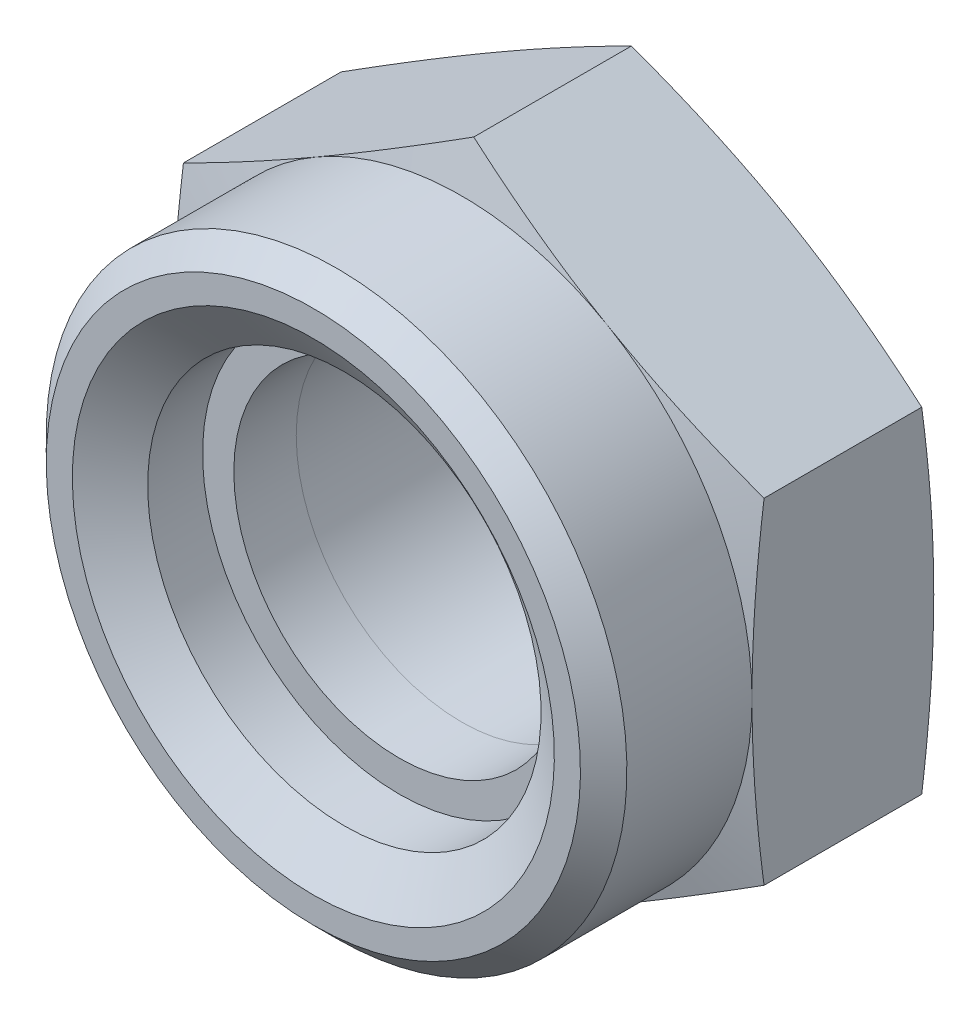
from build123d import *
from OCP.BRepFilletAPI import BRepFilletAPI_MakeChamfer

# Parameters (mm, degrees)
SKETCH_1_R          = 5.0528125
EXTRUDE_204_DEPTH   = 5.7
SKETCH_8_OUTSIDE_W  = 142.394
SKETCH_8_OUTSIDE_H  = 145.136
SKETCH_8_OUTSIDE_R  = 8.3
CUT_EXTRUDE_4_DEPTH = 15.692260718
CUT_EXTRUDE_4_DRAFT = -75
SKETCH_11_R         = 17.73
SKETCH_11_R_2       = 8.865
CUT_EXTRUDE_5_DEPTH = 1
CUT_EXTRUDE_5_DRAFT = -75
SKETCH_10_W         = 1.90609375
SKETCH_10_H         = 1.90609375
CHAMFER_1_SIZE      = 0.7092
CHAMFER_2_SIZE      = 0.9471875
CHAMFER_2_SIZE2     = 1.35272394


with BuildPart() as part:
    # 草图1 → Extrude 204 (new body)
    with BuildSketch(Plane.XY):
        Polygon((0, 10.236420273), (-8.865, 5.118210136), (-8.865, -5.118210136), (0, -10.236420273), (8.865, -5.118210136), (8.865, 5.118210136), align=None)
        Circle(SKETCH_1_R, mode=Mode.SUBTRACT)
    extrude(amount=EXTRUDE_204_DEPTH)


with BuildPart() as cut_extrude_4_tool:
    # 草图8 outside → 切除-拉伸4 (with draft: the straight prism first)
    with BuildSketch(Plane(origin=(0, 0, 0), x_dir=(-1, 0, 0), z_dir=(0, 0, -1))):
        Rectangle(SKETCH_8_OUTSIDE_W, SKETCH_8_OUTSIDE_H)
        Circle(SKETCH_8_OUTSIDE_R, mode=Mode.SUBTRACT)
    extrude(amount=-CUT_EXTRUDE_4_DEPTH)
    # 切除-拉伸4: the draft: its side faces are tilted about the plane it starts from
    cut_extrude_4_sides = [cut_extrude_4_tool.faces().sort_by_distance(p)[0] for p in [
        (0, -72.568, 7.846130359),
        (-71.197, 0, 7.846130359),
        (0, 72.568, 7.846130359),
        (71.197, 0, 7.846130359),
        (8.3, 0, 7.846130359),
    ]]
    draft(cut_extrude_4_sides, Plane(origin=(0, 0, 0), x_dir=(-1, 0, 0), z_dir=(0, 0, -1)), CUT_EXTRUDE_4_DRAFT)


with BuildPart() as part_1:
    add(part.part)

    # 切除-拉伸4: cut by cut_extrude_4_tool
    add(cut_extrude_4_tool.part, mode=Mode.SUBTRACT)


with BuildPart() as cut_extrude_5_tool:
    # 草图11 → 切除-拉伸5 (with draft: the straight prism first)
    with BuildSketch(Plane.XY.offset(5.7)):
        Circle(SKETCH_11_R)
        Circle(SKETCH_11_R_2, mode=Mode.SUBTRACT)
    extrude(amount=-CUT_EXTRUDE_5_DEPTH)
    # 切除-拉伸5: the draft: its side faces are tilted about the plane it starts from
    cut_extrude_5_sides = [cut_extrude_5_tool.faces().sort_by_distance(p)[0] for p in [
        (-17.73, 0, 5.2),
        (-8.865, 0, 5.2),
    ]]
    draft(cut_extrude_5_sides, Plane.XY.offset(5.7), CUT_EXTRUDE_5_DRAFT)


with BuildPart() as part_2:
    add(part_1.part)

    # 切除-拉伸5: cut by cut_extrude_5_tool
    add(cut_extrude_5_tool.part, mode=Mode.SUBTRACT)

    # 草图9 → 旋转1 (revolve)
    with BuildSketch(Plane(origin=(0, 0, 0), x_dir=(0, 0, -1), z_dir=(1, 0, 0))):
        Polygon((-5.7, 8.865), (-10.23, 8.865), (-10.23, 6.005859375), (-7.60609375, 6.005859375), (-7.60609375, 6.95890625), (-5.7, 6.95890625), align=None)
    revolve(axis=Axis((0, 0, 0), (0, 0, 1)))

    # 倒角1
    chamfer_1_edges = [part_2.edges().sort_by_distance(p)[0] for p in [
        (0, -8.865, 10.23),
    ]]
    chamfer(chamfer_1_edges, length=CHAMFER_1_SIZE)

    # 倒角2: one chamfer whose edges measure the first distance from different faces: ONE call of the kernel's chamfer builder (chamfer() names one face for all edges)
    chamfer_2_edges_1 = [part_2.edges().sort_by_distance(p)[0] for p in [
        (-5.0528125, 0, 0),
    ]]
    chamfer_2_side_1 = [part_2.faces().sort_by_distance(p)[0] for p in [
        (-5.0528125, 0, 2.85),
    ]]
    chamfer_2_edges_2 = [part_2.edges().sort_by_distance(p)[0] for p in [
        (0, -6.005859375, 10.23),
    ]]
    chamfer_2_side_2 = [part_2.faces().sort_by_distance(p)[0] for p in [
        (0, -6.005859375, 8.918046875),
    ]]
    chamfer_2 = BRepFilletAPI_MakeChamfer(part_2.part.solid().wrapped)
    for e in chamfer_2_edges_1:
        chamfer_2.Add(CHAMFER_2_SIZE, CHAMFER_2_SIZE2, e.wrapped, chamfer_2_side_1[0].wrapped)  # the first distance lies on this face
    for e in chamfer_2_edges_2:
        chamfer_2.Add(CHAMFER_2_SIZE, CHAMFER_2_SIZE2, e.wrapped, chamfer_2_side_2[0].wrapped)  # the first distance lies on this face
    add(Compound.cast(chamfer_2.Shape()), mode=Mode.REPLACE)


with BuildPart() as body_2:
    # 草图10 → 旋转2 (revolve)
    with BuildSketch(Plane(origin=(0, 0, 0), x_dir=(0, 0, -1), z_dir=(1, 0, 0))):
        with Locations((-6.653046875, 6.005859375)):
            Rectangle(SKETCH_10_W, SKETCH_10_H)
    revolve(axis=Axis((0, 0, 0), (0, 0, 1)))


solid = Compound([part_2.part, body_2.part])
